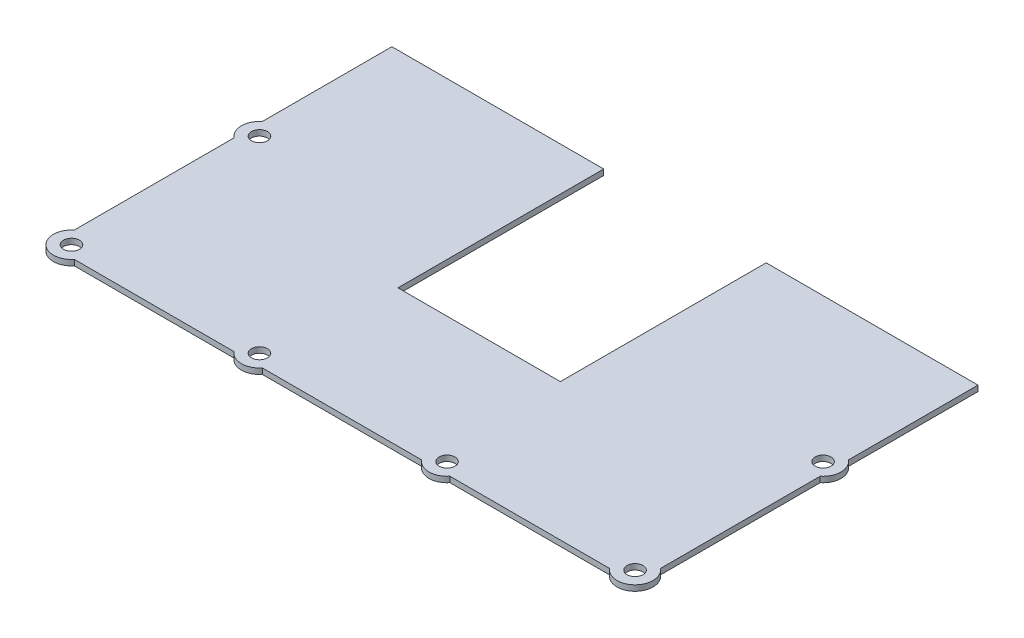
from build123d import *

# Parameters (mm, degrees)
SKETCH1_R           = 2.2479
BOSS_EXTRUDE1_DEPTH = 1.5875


with BuildPart() as part:
    # Sketch1 → Boss-Extrude1 (new body)
    with BuildSketch(Plane(origin=(0, 0, 0), x_dir=(1, 0, 0), z_dir=(0, 1, 0))):
        with BuildLine():
            Line((59.6265, 0), (0, 0))
            Line((0, 0), (0, -36.474509804))
            ThreePointArc((0, -36.474509804), (-1.905, -40.440083533), (0, -44.405657262))
            Line((0, -44.405657262), (0, -89.391176471))
            ThreePointArc((0, -89.391176471), (-0.417102448, -96.948852648), (7.140573729, -96.5317502))
            Line((7.140573729, -96.5317502), (52.126092938, -96.5317502))
            ThreePointArc((52.126092938, -96.5317502), (56.091666667, -98.4367502), (60.057240396, -96.5317502))
            Line((60.057240396, -96.5317502), (63.5, -96.5317502))
            Line((63.5, -96.5317502), (69.85, -96.5317502))
            Line((69.85, -96.5317502), (95.25, -96.5317502))
            Line((95.25, -96.5317502), (101.6, -96.5317502))
            Line((101.6, -96.5317502), (104.917251774, -96.5317502))
            ThreePointArc((104.917251774, -96.5317502), (108.882825503, -98.4367502), (112.848399232, -96.5317502))
            Line((112.848399232, -96.5317502), (157.833918441, -96.5317502))
            ThreePointArc((157.833918441, -96.5317502), (165.391594618, -96.948852648), (164.97449217, -89.391176471))
            Line((164.97449217, -89.391176471), (164.97449217, -44.405657262))
            ThreePointArc((164.97449217, -44.405657262), (166.87949217, -40.440083533), (164.97449217, -36.474509804))
            Line((164.97449217, -36.474509804), (164.97449217, 0))
            Line((164.97449217, 0), (105.34799217, 0))
            Line((105.34799217, 0), (105.34799217, -57.9237502))
            Line((105.34799217, -57.9237502), (59.6265, -57.9237502))
            Line((59.6265, -57.9237502), (59.6265, 0))
        make_face()
        with Locations((3.175, -40.440083533)):
            Circle(SKETCH1_R, mode=Mode.SUBTRACT)
        with Locations((3.175, -93.3567502)):
            Circle(SKETCH1_R, mode=Mode.SUBTRACT)
        with Locations((56.091666667, -93.3567502)):
            Circle(SKETCH1_R, mode=Mode.SUBTRACT)
        with Locations((108.882825503, -93.3567502)):
            Circle(SKETCH1_R, mode=Mode.SUBTRACT)
        with Locations((161.79949217, -93.3567502)):
            Circle(SKETCH1_R, mode=Mode.SUBTRACT)
        with Locations((161.79949217, -40.440083533)):
            Circle(SKETCH1_R, mode=Mode.SUBTRACT)
    extrude(amount=BOSS_EXTRUDE1_DEPTH)


solid = part.part
